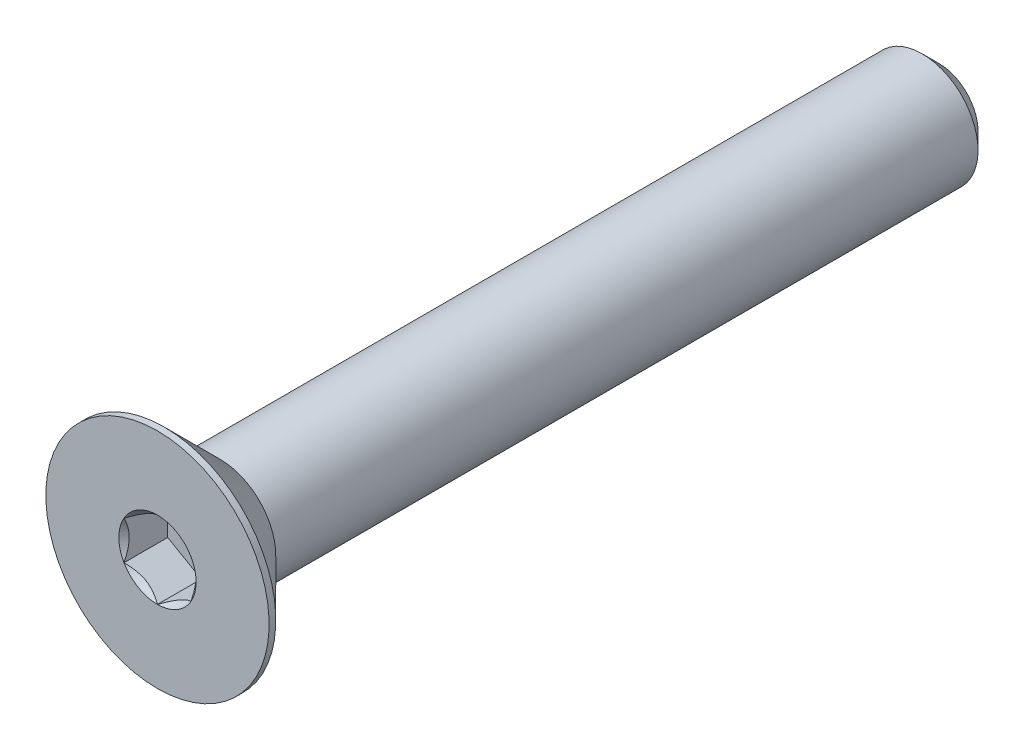
from build123d import *

# Parameters (mm, degrees)
SKETCH3_W          = 35
SKETCH3_H          = 2.5
CHAMFER1_SIZE      = 0.75
CUT_EXTRUDE1_DEPTH = 1.96
SKETCH9_R          = 1.732050808
CUT_EXTRUDE2_DEPTH = 1.96
CUT_EXTRUDE2_DRAFT = -45


with BuildPart() as part:
    # Sketch3 → Revolve1 (revolve)
    with BuildSketch(Plane(origin=(0, 0, 0), x_dir=(0, 0, -1), z_dir=(1, 0, 0))):
        with Locations((0, 1.25)):
            Rectangle(SKETCH3_W, SKETCH3_H)
    revolve(axis=Axis((0, 0, -17.5), (0, 0, 1)))

    # Chamfer1
    chamfer1_edges = [part.edges().sort_by_distance(p)[0] for p in [
        (0, -2.5, -17.5),
    ]]
    chamfer(chamfer1_edges, length=CHAMFER1_SIZE)

    # Sketch6 → Revolve2 (revolve)
    with BuildSketch(Plane(origin=(0, 0, 0), x_dir=(0, 0, -1), z_dir=(1, 0, 0))):
        Polygon((-17.5, 5), (-17.2, 5), (-14.7, 2.5), (-14.7, 0), (-17.5, 0), align=None)
    revolve(axis=Axis((0, 0, -17.5), (0, 0, 1)))

    # Sketch8 → Cut-Extrude1 (cut)
    with BuildSketch(Plane.XY.offset(17.5)):
        Polygon((0, 1.732050808), (-1.5, 0.866025404), (-1.5, -0.866025404), (0, -1.732050808), (1.5, -0.866025404), (1.5, 0.866025404), align=None)
    extrude(amount=-CUT_EXTRUDE1_DEPTH, mode=Mode.SUBTRACT)


with BuildPart() as cut_extrude2_tool:
    # Sketch9 → Cut-Extrude2 (with draft: the straight prism first)
    with BuildSketch(Plane.XY.offset(17.5)):
        Circle(SKETCH9_R)
    extrude(amount=-CUT_EXTRUDE2_DEPTH)
    # Cut-Extrude2: the draft: its side faces are tilted about the plane it starts from
    cut_extrude2_sides = [cut_extrude2_tool.faces().sort_by_distance(p)[0] for p in [
        (-1.732050808, 0, 16.52),
    ]]
    draft(cut_extrude2_sides, Plane.XY.offset(17.5), CUT_EXTRUDE2_DRAFT)


with BuildPart() as part_1:
    add(part.part)

    # Cut-Extrude2: cut by cut_extrude2_tool
    add(cut_extrude2_tool.part, mode=Mode.SUBTRACT)


solid = part_1.part
